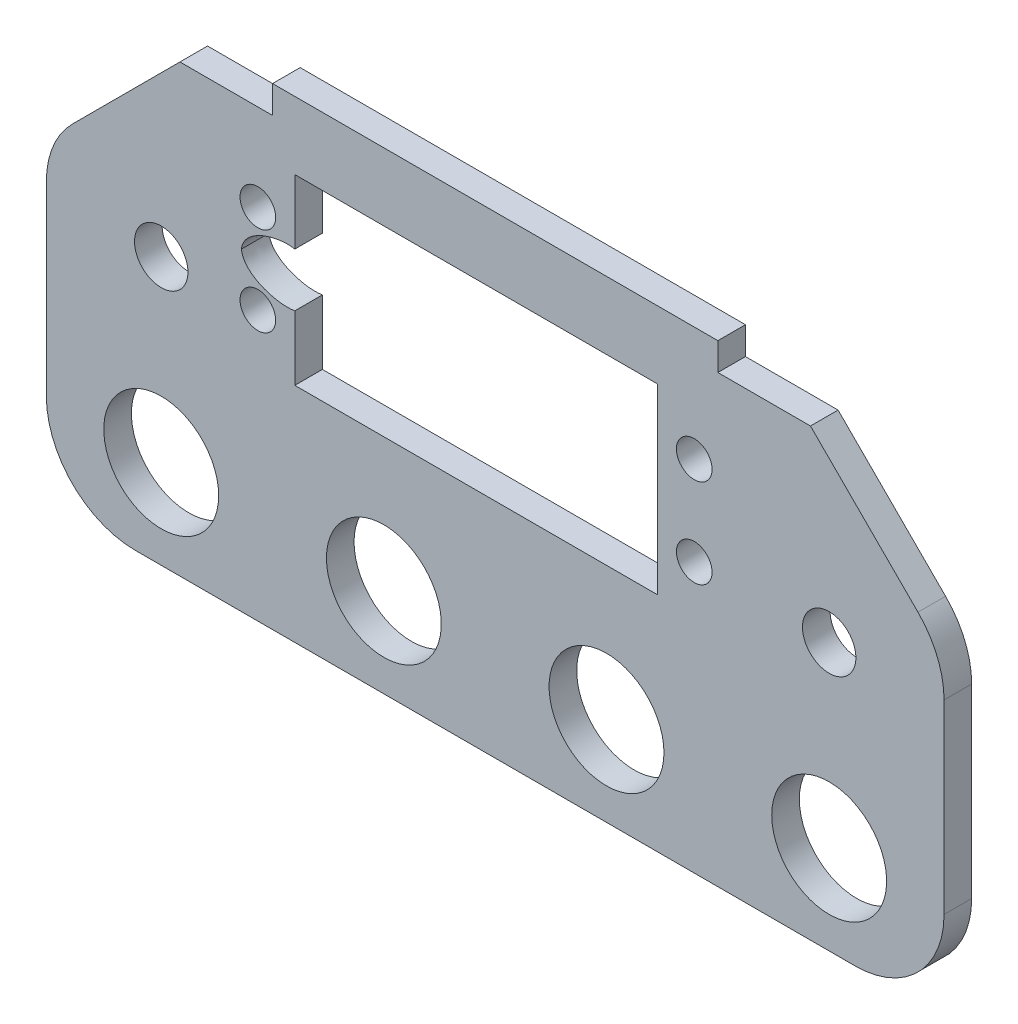
from build123d import *

# Parameters (mm, degrees)
SKETCH4_R           = 6.45
BOSS_EXTRUDE3_DEPTH = 3.1
SKETCH5_R           = 2
SKETCH5_R_2         = 3
CUT_EXTRUDE4_DEPTH  = 4.1
FILLET1_R           = 10
SKETCH6_W           = 50
SKETCH6_H           = 3.1
BOSS_EXTRUDE4_DEPTH = 3.1
CHAMFER1_SIZE       = 15
FILLET2_R           = 10


with BuildPart() as part:
    # Sketch4 → Boss-Extrude3 (new body)
    with BuildSketch(Plane.XY):
        Polygon((50.399999987, -5.000794186), (-50.399999987, -5.000794186), (-50.399999987, 44.999205814), (-0.399999987, 44.999205814), (19.600000013, 44.999205814), (50.399999987, 44.999205814), align=None)
        with Locations((12.5, 5.000000001)):
            Circle(SKETCH4_R, mode=Mode.SUBTRACT)
        with Locations((-37.499999987, 4.999205814)):
            Circle(SKETCH4_R, mode=Mode.SUBTRACT)
        with Locations((37.499999987, 4.999205814)):
            Circle(SKETCH4_R, mode=Mode.SUBTRACT)
        with Locations((-12.5, 5.000000001)):
            Circle(SKETCH4_R, mode=Mode.SUBTRACT)
    extrude(amount=BOSS_EXTRUDE3_DEPTH)

    # Sketch5 → Cut-Extrude4 (cut, through all)
    with BuildSketch(Plane.XY):
        with Locations((22.35, 35.250000001)):
            Circle(SKETCH5_R)
        with Locations((22.35, 25.250000001)):
            Circle(SKETCH5_R)
        with Locations((-26.65, 25.250000001)):
            Circle(SKETCH5_R)
        with Locations((-26.65, 35.250000001)):
            Circle(SKETCH5_R)
        with Locations((37.5, 24.999205814)):
            Circle(SKETCH5_R_2)
        with Locations((-37.5, 24.999205814)):
            Circle(SKETCH5_R_2)
        with BuildLine():
            Line((-22.5, 20.000000001), (18.2, 20.000000001))
            Line((18.2, 20.000000001), (18.2, 40.500000001))
            Line((18.2, 40.500000001), (-22.5, 40.500000001))
            Line((-22.5, 40.500000001), (-22.5, 33.250000001))
            add(Edge.make_bspline(
                [(-28.5, 30.250000001), (-28.211982464, 32.604979652), (-24.313004512, 33.611534185), (-22.5, 33.250000001)],
                knots=[0, 0, 0, 0, 1, 1, 1, 1], degree=3))
            add(Edge.make_bspline(
                [(-28.5, 30.250000001), (-28.211982464, 27.89502035), (-24.313004512, 26.888465817), (-22.5, 27.250000001)],
                knots=[0, 0, 0, 0, 1, 1, 1, 1], degree=3))
            Line((-22.5, 27.250000001), (-22.5, 20.000000001))
        make_face()
    extrude(amount=CUT_EXTRUDE4_DEPTH, mode=Mode.SUBTRACT)

    # Fillet1
    fillet1_edges = [part.edges().sort_by_distance(p)[0] for p in [
        (50.399999987, -5.000794186, 1.55),
        (-50.399999987, -5.000794186, 1.55),
    ]]
    fillet(fillet1_edges, radius=FILLET1_R)

    # Sketch6 → Boss-Extrude4 (add, through all)
    with BuildSketch(Plane.XY.offset(3.1)):
        with Locations((0, 46.549205814)):
            Rectangle(SKETCH6_W, SKETCH6_H)
    extrude(amount=-BOSS_EXTRUDE4_DEPTH)

    # Chamfer1
    chamfer1_edges = [part.edges().sort_by_distance(p)[0] for p in [
        (50.399999987, 44.999205814, 1.55),
        (-50.399999987, 44.999205814, 1.55),
    ]]
    chamfer(chamfer1_edges, length=CHAMFER1_SIZE)

    # Fillet2
    fillet2_edges = [part.edges().sort_by_distance(p)[0] for p in [
        (-50.399999987, 29.999205814, 1.55),
        (50.399999987, 29.999205814, 1.55),
    ]]
    fillet(fillet2_edges, radius=FILLET2_R)


solid = part.part
